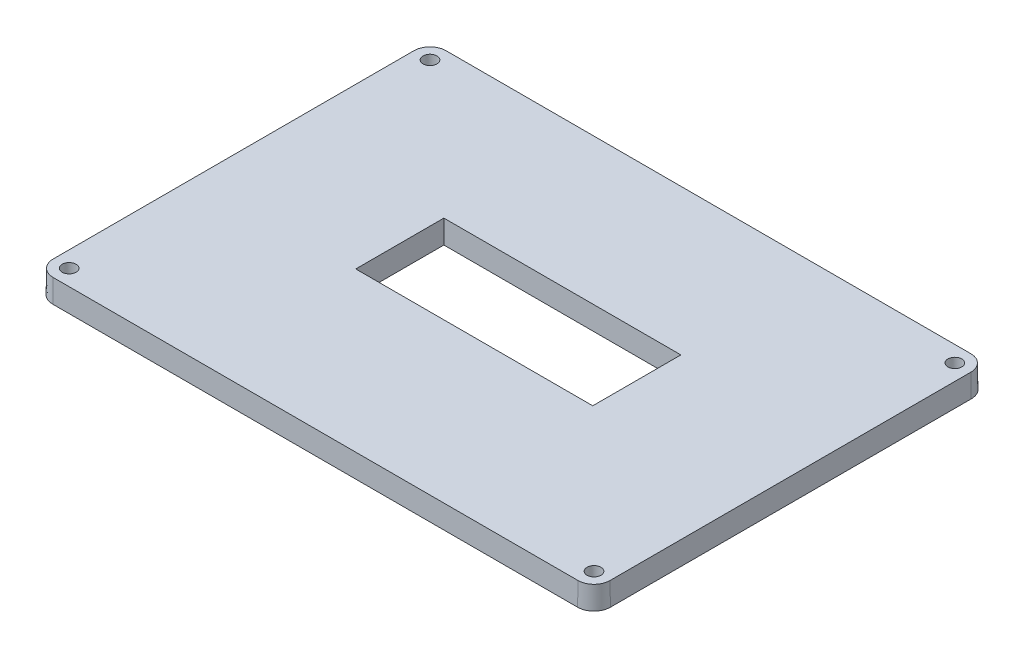
from build123d import *

# Parameters (mm, degrees)
SKETCH1_W           = 170
SKETCH1_H           = 120
BOSS_EXTRUDE1_DEPTH = 7
SKETCH2_W           = 72
SKETCH2_H           = 26.620567464
CUT_EXTRUDE1_DEPTH  = 7
SKETCH3_R           = 2
CUT_EXTRUDE5_DEPTH  = 7
SKETCH7_R           = 2
CUT_EXTRUDE7_DEPTH  = 10
SKETCH6_R           = 2
CUT_EXTRUDE10_DEPTH = 10
SKETCH9_R           = 2
CUT_EXTRUDE11_DEPTH = 10
FILLET1_R           = 5
DRAFT1_ANGLE        = 1


with BuildPart() as part:
    # Sketch1 → Boss-Extrude1 (new body)
    with BuildSketch(Plane(origin=(0, 0, 0), x_dir=(1, 0, 0), z_dir=(0, 1, 0))):
        Rectangle(SKETCH1_W, SKETCH1_H)
    extrude(amount=BOSS_EXTRUDE1_DEPTH)

    # Sketch2 → Cut-Extrude1 (cut)
    with BuildSketch(Plane(origin=(0, 7, 0), x_dir=(1, 0, 0), z_dir=(0, 1, 0))):
        with Locations((0, 1.926488435)):
            Rectangle(SKETCH2_W, SKETCH2_H)
    extrude(amount=-CUT_EXTRUDE1_DEPTH, mode=Mode.SUBTRACT)

    # Sketch3 → Cut-Extrude5 (cut)
    with BuildSketch(Plane(origin=(0, 7, 0), x_dir=(1, 0, 0), z_dir=(0, 1, 0))):
        with Locations(Location((-80, 55, 0), (0, 0, 270))):
            Circle(SKETCH3_R)
    extrude(amount=-CUT_EXTRUDE5_DEPTH, mode=Mode.SUBTRACT)

    # Sketch7 → Cut-Extrude7 (cut)
    with BuildSketch(Plane(origin=(0, 7, 0), x_dir=(1, 0, 0), z_dir=(0, 1, 0))):
        with Locations(Location((-80, -55, 0), (0, 0, 270))):
            Circle(SKETCH7_R)
    extrude(amount=-CUT_EXTRUDE7_DEPTH, mode=Mode.SUBTRACT)

    # Sketch6 → Cut-Extrude10 (cut)
    with BuildSketch(Plane(origin=(0, 7, 0), x_dir=(1, 0, 0), z_dir=(0, 1, 0))):
        with Locations(Location((80, 55, 0), (0, 0, 270))):
            Circle(SKETCH6_R)
    extrude(amount=-CUT_EXTRUDE10_DEPTH, mode=Mode.SUBTRACT)

    # Sketch9 → Cut-Extrude11 (cut)
    with BuildSketch(Plane(origin=(0, 7, 0), x_dir=(1, 0, 0), z_dir=(0, 1, 0))):
        with Locations(Location((80, -55, 0), (0, 0, 270))):
            Circle(SKETCH9_R)
    extrude(amount=-CUT_EXTRUDE11_DEPTH, mode=Mode.SUBTRACT)

    # Fillet1
    fillet1_edges = [part.edges().sort_by_distance(p)[0] for p in [
        (-85, 3.5, -60),
        (85, 3.5, -60),
        (85, 3.5, 60),
        (-85, 3.5, 60),
    ]]
    fillet(fillet1_edges, radius=FILLET1_R)

    # Draft1
    draft1_faces = [part.faces().sort_by_distance(p)[0] for p in [
        (-83.535533906, 3.5, 58.535533906),
        (-85, 3.5, 0),
        (-83.535533906, 3.5, -58.535533906),
        (0, 3.5, -60),
        (83.535533906, 3.5, -58.535533906),
        (85, 3.5, 0),
        (83.535533906, 3.5, 58.535533906),
        (0, 3.5, 60),
        (-80, 3.5, 53),
        (80, 3.5, 53),
        (80, 3.5, -57),
        (-80, 3.5, -57),
        (-36, 3.5, -1.926488435),
        (0, 3.5, -15.236772167),
        (36, 3.5, -1.926488435),
        (0, 3.5, 11.383795297),
    ]]
    draft(draft1_faces, Plane.ZX, DRAFT1_ANGLE)


solid = part.part
